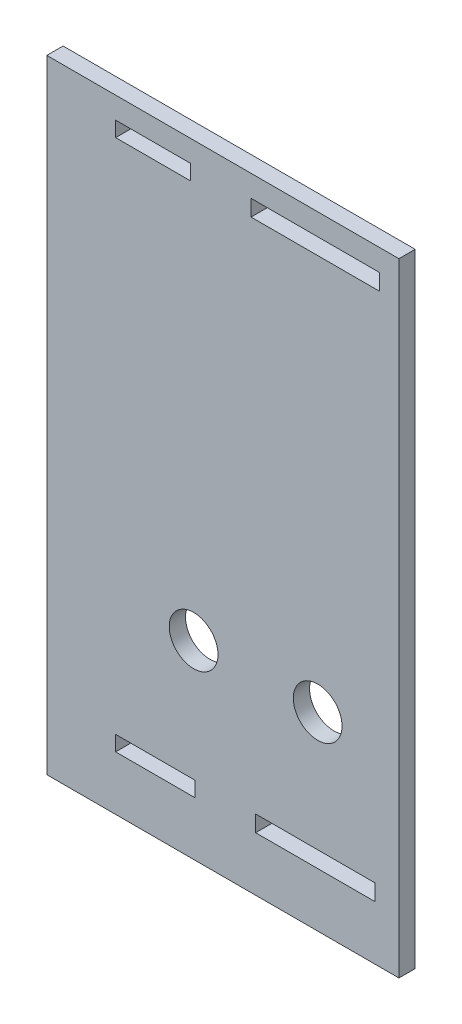
from build123d import *

# Parameters (mm, degrees)
CROQUIS1_W              = 100
CROQUIS1_H              = 115
CROQUIS1_R              = 4.5
CROQUIS1_W_2            = 14.7
CROQUIS1_H_2            = 2.8
CROQUIS1_W_3            = 22.05
CROQUIS1_H_3            = 3
CROQUIS1_W_4            = 13.85
CROQUIS1_W_5            = 23.75
SALIENTE_EXTRUIR1_DEPTH = 3
CROQUIS2_W              = 35
CROQUIS2_H              = 115
CORTAR_EXTRUIR1_DEPTH   = 4


with BuildPart() as part:
    # Croquis1 → Saliente-Extruir1 (new body)
    with BuildSketch(Plane.XY):
        Rectangle(CROQUIS1_W, CROQUIS1_H)
        with Locations((0, -22.5)):
            Circle(CROQUIS1_R, mode=Mode.SUBTRACT)
        with Locations((-22.9, -22.5)):
            Circle(CROQUIS1_R, mode=Mode.SUBTRACT)
        with Locations((24.1, -22.5)):
            Circle(CROQUIS1_R, mode=Mode.SUBTRACT)
        with Locations((29.95, -46.1)):
            Rectangle(CROQUIS1_W_2, CROQUIS1_H_2, mode=Mode.SUBTRACT)
        with Locations((-29.95, -46.1)):
            Rectangle(CROQUIS1_W_2, CROQUIS1_H_2, mode=Mode.SUBTRACT)
        with Locations((-0.425, -46)):
            Rectangle(CROQUIS1_W_3, CROQUIS1_H_3, mode=Mode.SUBTRACT)
        with Locations((30.375, 52.1)):
            Rectangle(CROQUIS1_W_4, CROQUIS1_H_2, mode=Mode.SUBTRACT)
        with Locations((-30.375, 52.1)):
            Rectangle(CROQUIS1_W_4, CROQUIS1_H_2, mode=Mode.SUBTRACT)
        with Locations((-0.425, 52)):
            Rectangle(CROQUIS1_W_5, CROQUIS1_H_3, mode=Mode.SUBTRACT)
    extrude(amount=SALIENTE_EXTRUIR1_DEPTH)

    # Croquis2 → Cortar-Extruir1 (cut, through all)
    with BuildSketch(Plane.XY.offset(3)):
        with Locations((32.5, 0)):
            Rectangle(CROQUIS2_W, CROQUIS2_H)
    extrude(amount=-CORTAR_EXTRUIR1_DEPTH, mode=Mode.SUBTRACT)


solid = part.part
